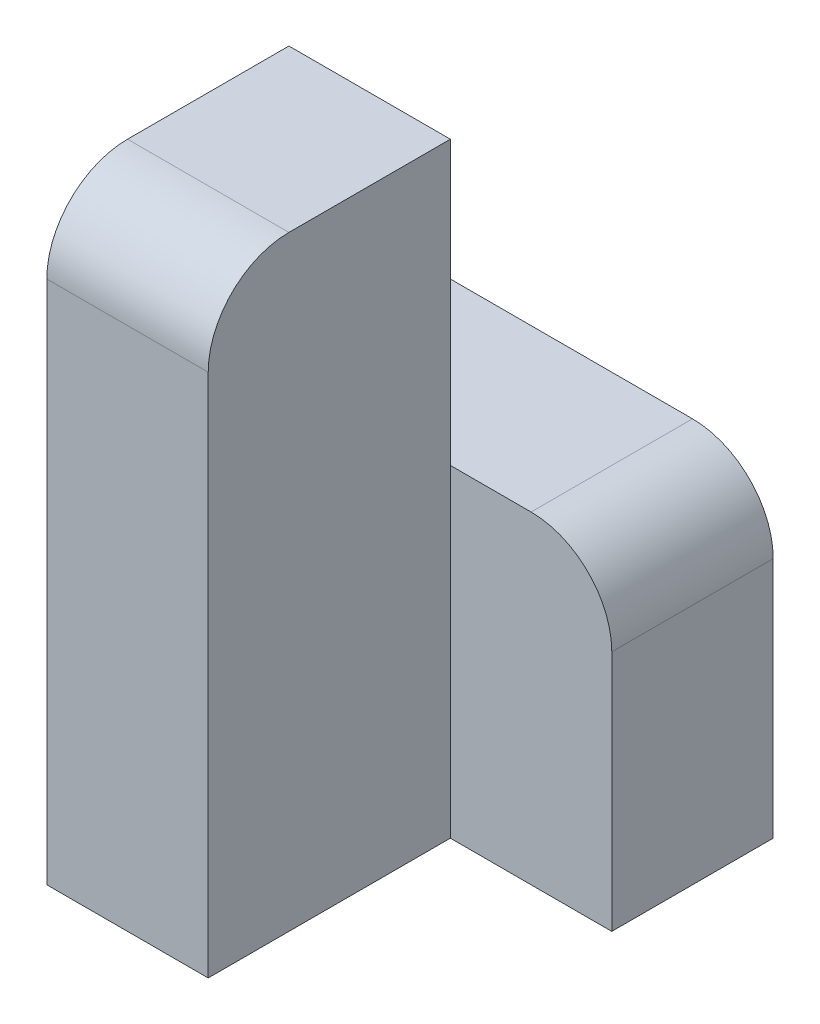
from build123d import *

# Parameters (mm, degrees)
SKETCH1_W           = 20
SKETCH1_H           = 75
BOSS_EXTRUDE1_DEPTH = 30
SKETCH2_W           = 40
SKETCH2_H           = 40
BOSS_EXTRUDE2_DEPTH = 20
FILLET1_R           = 10


with BuildPart() as part:
    # Sketch1 → Boss-Extrude1 (new body)
    with BuildSketch(Plane.XY):
        with Locations((-20, -37.5)):
            Rectangle(SKETCH1_W, SKETCH1_H)
    extrude(amount=BOSS_EXTRUDE1_DEPTH)

    # Sketch2 → Boss-Extrude2 (add)
    with BuildSketch(Plane.XY):
        with Locations((-10, -55)):
            Rectangle(SKETCH2_W, SKETCH2_H)
    extrude(amount=-BOSS_EXTRUDE2_DEPTH)

    # Fillet1
    fillet1_edges = [part.edges().sort_by_distance(p)[0] for p in [
        (10, -35, -10),
        (-20, 0, 30),
    ]]
    fillet(fillet1_edges, radius=FILLET1_R)


solid = part.part
